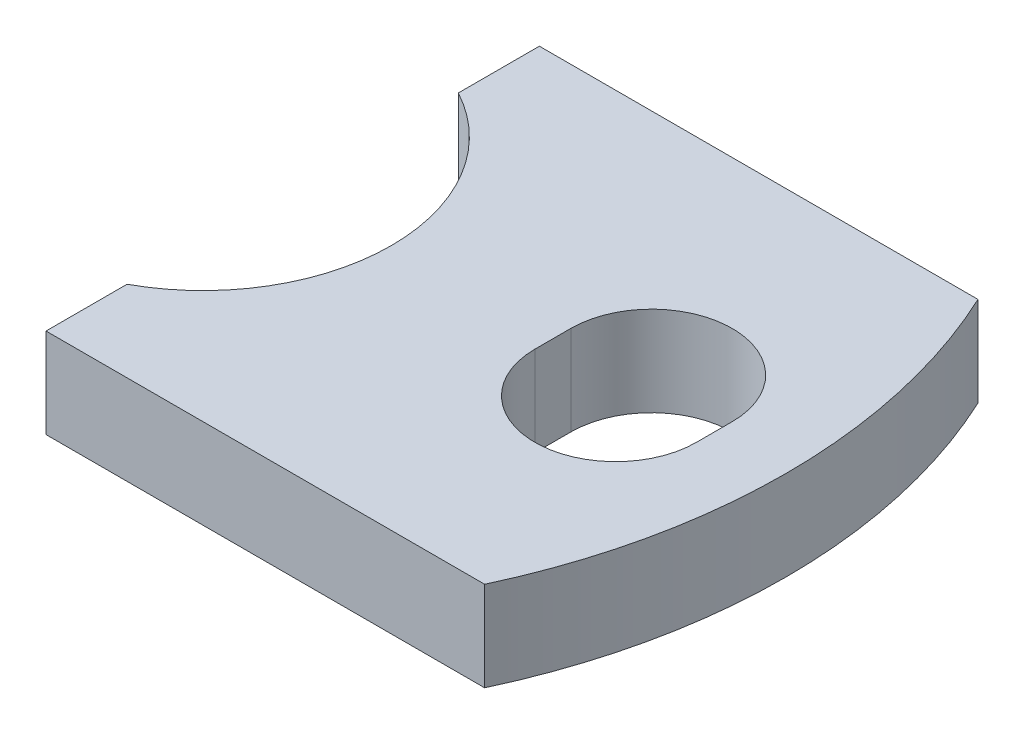
from build123d import *

# Parameters (mm, degrees)
SKETCH2_W           = 5.5
SKETCH2_H           = 5.5
BOSS_EXTRUDE1_DEPTH = 1
CUT_EXTRUDE1_DEPTH  = 2
CUT_EXTRUDE2_DEPTH  = 2
CUT_EXTRUDE3_DEPTH  = 1


with BuildPart() as part:
    # Sketch2 → Boss-Extrude1 (new body)
    with BuildSketch(Plane(origin=(0, 0, 0), x_dir=(1, 0, 0), z_dir=(0, 1, 0))):
        Rectangle(SKETCH2_W, SKETCH2_H)
    extrude(amount=BOSS_EXTRUDE1_DEPTH)

    # Sketch3 → Cut-Extrude1 (cut, through all)
    with BuildSketch(Plane(origin=(0, 1, 0), x_dir=(1, 0, 0), z_dir=(0, 1, 0))):
        with BuildLine():
            Line((0.15, -0.2), (0.15, 0.2))
            ThreePointArc((0.15, 0.2), (1.05, 1.1), (1.95, 0.2))
            Line((1.95, 0.2), (1.95, -0.2))
            ThreePointArc((1.95, -0.2), (1.05, -1.1), (0.15, -0.2))
        make_face()
    extrude(amount=-CUT_EXTRUDE1_DEPTH, mode=Mode.SUBTRACT)

    # Sketch4 → Cut-Extrude2 (cut, through all)
    with BuildSketch(Plane(origin=(0, 1, 0), x_dir=(1, 0, 0), z_dir=(0, 1, 0))):
        with BuildLine():
            Line((-2.75, 1.846618531), (-2.75, -1.846618531))
            ThreePointArc((-2.75, -1.846618531), (-1.65, 0), (-2.75, 1.846618531))
        make_face()
    extrude(amount=-CUT_EXTRUDE2_DEPTH, mode=Mode.SUBTRACT)

    # Sketch5 → Cut-Extrude3 (cut)
    with BuildSketch(Plane(origin=(0, 1, 0), x_dir=(1, 0, 0), z_dir=(0, 1, 0))):
        with BuildLine():
            Line((3.85, -2.75), (3.85, 2.75))
            Line((3.85, 2.75), (2.139609495, 2.75))
            ThreePointArc((2.139609495, 2.75), (2.75, 0), (2.139609495, -2.75))
            Line((2.139609495, -2.75), (3.85, -2.75))
        make_face()
    extrude(amount=-CUT_EXTRUDE3_DEPTH, mode=Mode.SUBTRACT)


solid = part.part
